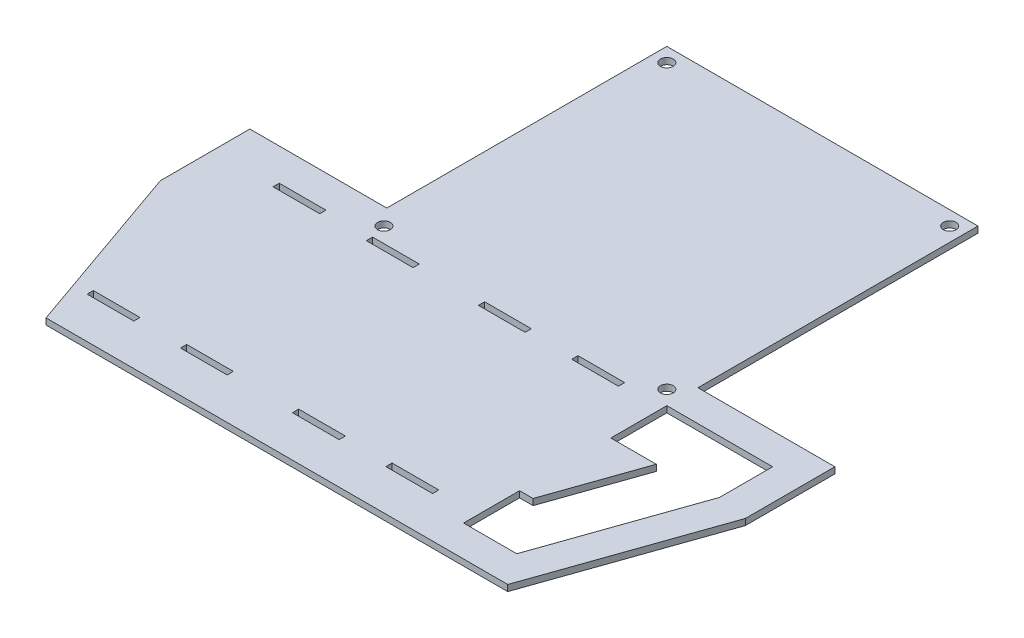
from build123d import *

# Parameters (mm, degrees)
SALIENTE_EXTRUIR1_DEPTH = 2
CROQUIS2_R              = 2.05
CORTAR_EXTRUIR1_DEPTH   = 3
CORTAR_EXTRUIR3_REACH   = 4
CORTAR_EXTRUIR4_REACH   = 4
CROQUIS5_W              = 15
CROQUIS5_H              = 2


with BuildPart() as part:
    # Croquis1 → Saliente-Extruir1 (new body)
    with BuildSketch(Plane(origin=(0, 0, 0), x_dir=(1, 0, 0), z_dir=(0, 1, 0))):
        Polygon((94, -40), (50, -40), (50, 50), (-50, 50), (-50, -40), (-94, -40), (-94, -68.768453788), (-74.193903104, -125.32), (74.193903104, -125.32), (94, -68.768453788), align=None)
    extrude(amount=SALIENTE_EXTRUIR1_DEPTH)

    # Croquis2 → Cortar-Extruir1 (cut, through all)
    with BuildSketch(Plane(origin=(0, 2, 0), x_dir=(1, 0, 0), z_dir=(0, 1, 0))):
        with Locations((-45.45, -45.45)):
            Circle(CROQUIS2_R)
        with Locations((45.45, -45.45)):
            Circle(CROQUIS2_R)
        with Locations((-45.45, 45.45)):
            Circle(CROQUIS2_R)
        with Locations((45.45, 45.45)):
            Circle(CROQUIS2_R)
    extrude(amount=-CORTAR_EXTRUIR1_DEPTH, mode=Mode.SUBTRACT)

    # Croquis4 → Cortar-Extruir3 (cut, up to next)
    with BuildSketch(Plane(origin=(0, 2, 0), x_dir=(1, 0, 0), z_dir=(0, 1, 0)), mode=Mode.PRIVATE) as cortar_extruir3_sk1:
        Polygon((50, -68), (64.601532017, -68), (54.332763081, -97.32), (50, -97.32), (50, -115.32), (67.10063881, -115.32), (84, -67.067938511), (84, -50), (50, -50), align=None)
    cortar_extruir3_tool1 = extrude(cortar_extruir3_sk1.sketch, amount=-CORTAR_EXTRUIR3_REACH, mode=Mode.PRIVATE) & part.part
    add(cortar_extruir3_tool1.solids().sort_by_distance((66.115396, 2, 78.737968))[0], mode=Mode.SUBTRACT)

    # Croquis5 → Cortar-Extruir4 (cut, up to next)
    with BuildSketch(Plane(origin=(0, 2, 0), x_dir=(1, 0, 0), z_dir=(0, 1, 0)), mode=Mode.PRIVATE) as cortar_extruir4_sk1:
        with Locations((29.306096896, -51.35767988)):
            Rectangle(CROQUIS5_W, CROQUIS5_H)
    cortar_extruir4_tool1 = extrude(cortar_extruir4_sk1.sketch, amount=-CORTAR_EXTRUIR4_REACH, mode=Mode.PRIVATE) & part.part
    add(cortar_extruir4_tool1.solids().sort_by_distance((29.306097, 2, 51.35768))[0], mode=Mode.SUBTRACT)
    # Croquis5 → Cortar-Extruir4 (cut, up to next)
    with BuildSketch(Plane(origin=(0, 2, 0), x_dir=(1, 0, 0), z_dir=(0, 1, 0)), mode=Mode.PRIVATE) as cortar_extruir4_sk2:
        with Locations((-66.693903104, -51.35767988)):
            Rectangle(CROQUIS5_W, CROQUIS5_H)
    cortar_extruir4_tool2 = extrude(cortar_extruir4_sk2.sketch, amount=-CORTAR_EXTRUIR4_REACH, mode=Mode.PRIVATE) & part.part
    add(cortar_extruir4_tool2.solids().sort_by_distance((-66.693903, 2, 51.35768))[0], mode=Mode.SUBTRACT)
    # Croquis5 → Cortar-Extruir4 (cut, up to next)
    with BuildSketch(Plane(origin=(0, 2, 0), x_dir=(1, 0, 0), z_dir=(0, 1, 0)), mode=Mode.PRIVATE) as cortar_extruir4_sk3:
        with Locations((-36.693903104, -51.35767988)):
            Rectangle(CROQUIS5_W, CROQUIS5_H)
    cortar_extruir4_tool3 = extrude(cortar_extruir4_sk3.sketch, amount=-CORTAR_EXTRUIR4_REACH, mode=Mode.PRIVATE) & part.part
    add(cortar_extruir4_tool3.solids().sort_by_distance((-36.693903, 2, 51.35768))[0], mode=Mode.SUBTRACT)
    # Croquis5 → Cortar-Extruir4 (cut, up to next)
    with BuildSketch(Plane(origin=(0, 2, 0), x_dir=(1, 0, 0), z_dir=(0, 1, 0)), mode=Mode.PRIVATE) as cortar_extruir4_sk4:
        with Locations((-0.693903104, -51.35767988)):
            Rectangle(CROQUIS5_W, CROQUIS5_H)
    cortar_extruir4_tool4 = extrude(cortar_extruir4_sk4.sketch, amount=-CORTAR_EXTRUIR4_REACH, mode=Mode.PRIVATE) & part.part
    add(cortar_extruir4_tool4.solids().sort_by_distance((-0.693903, 2, 51.35768))[0], mode=Mode.SUBTRACT)
    # Croquis5 → Cortar-Extruir4 (cut, up to next)
    with BuildSketch(Plane(origin=(0, 2, 0), x_dir=(1, 0, 0), z_dir=(0, 1, 0)), mode=Mode.PRIVATE) as cortar_extruir4_sk5:
        with Locations((-66.693903104, -111.10767988)):
            Rectangle(CROQUIS5_W, CROQUIS5_H)
    cortar_extruir4_tool5 = extrude(cortar_extruir4_sk5.sketch, amount=-CORTAR_EXTRUIR4_REACH, mode=Mode.PRIVATE) & part.part
    add(cortar_extruir4_tool5.solids().sort_by_distance((-66.693903, 2, 111.10768))[0], mode=Mode.SUBTRACT)
    # Croquis5 → Cortar-Extruir4 (cut, up to next)
    with BuildSketch(Plane(origin=(0, 2, 0), x_dir=(1, 0, 0), z_dir=(0, 1, 0)), mode=Mode.PRIVATE) as cortar_extruir4_sk6:
        with Locations((-36.693903104, -111.10767988)):
            Rectangle(CROQUIS5_W, CROQUIS5_H)
    cortar_extruir4_tool6 = extrude(cortar_extruir4_sk6.sketch, amount=-CORTAR_EXTRUIR4_REACH, mode=Mode.PRIVATE) & part.part
    add(cortar_extruir4_tool6.solids().sort_by_distance((-36.693903, 2, 111.10768))[0], mode=Mode.SUBTRACT)
    # Croquis5 → Cortar-Extruir4 (cut, up to next)
    with BuildSketch(Plane(origin=(0, 2, 0), x_dir=(1, 0, 0), z_dir=(0, 1, 0)), mode=Mode.PRIVATE) as cortar_extruir4_sk7:
        with Locations((-0.693903104, -111.10767988)):
            Rectangle(CROQUIS5_W, CROQUIS5_H)
    cortar_extruir4_tool7 = extrude(cortar_extruir4_sk7.sketch, amount=-CORTAR_EXTRUIR4_REACH, mode=Mode.PRIVATE) & part.part
    add(cortar_extruir4_tool7.solids().sort_by_distance((-0.693903, 2, 111.10768))[0], mode=Mode.SUBTRACT)
    # Croquis5 → Cortar-Extruir4 (cut, up to next)
    with BuildSketch(Plane(origin=(0, 2, 0), x_dir=(1, 0, 0), z_dir=(0, 1, 0)), mode=Mode.PRIVATE) as cortar_extruir4_sk8:
        with Locations((29.306096896, -111.10767988)):
            Rectangle(CROQUIS5_W, CROQUIS5_H)
    cortar_extruir4_tool8 = extrude(cortar_extruir4_sk8.sketch, amount=-CORTAR_EXTRUIR4_REACH, mode=Mode.PRIVATE) & part.part
    add(cortar_extruir4_tool8.solids().sort_by_distance((29.306097, 2, 111.10768))[0], mode=Mode.SUBTRACT)


solid = part.part
